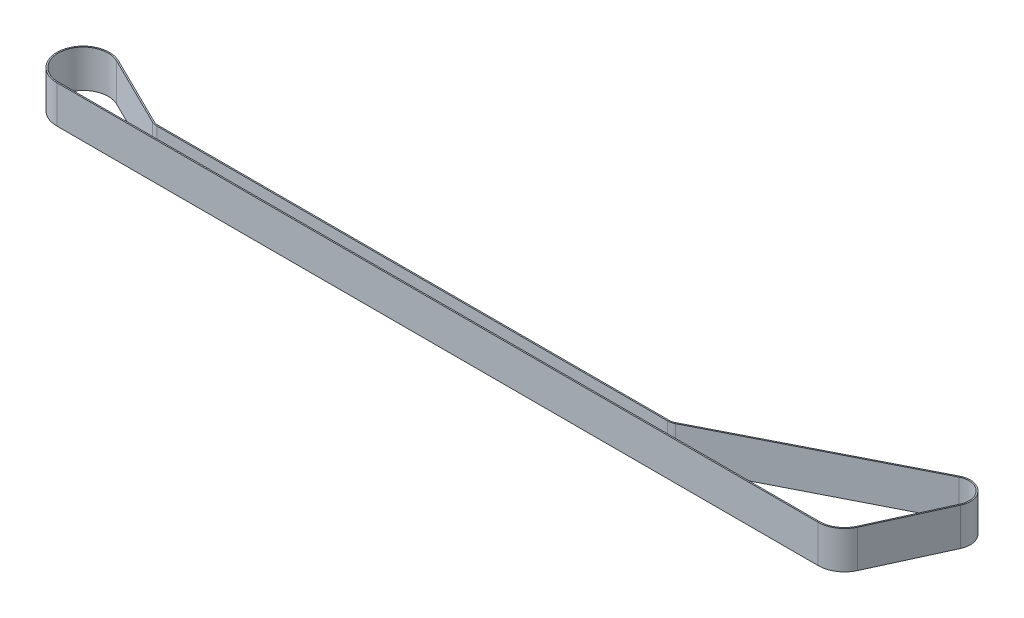
from build123d import *

# Parameters (mm, degrees)
BOSS_EXTRUDE1_DEPTH = 15


with BuildPart() as part:
    # Sketch1 → Boss-Extrude1 (new body)
    with BuildSketch(Plane(origin=(0, 0, 0), x_dir=(1, 0, 0), z_dir=(0, 1, 0))):
        with BuildLine():
            Line((238.84, -5), (35, -5))
            ThreePointArc((35, -5), (33.863075353, -4.869024784), (32.785714286, -4.482960938))
            Line((32.785714286, -4.482960938), (4.65, 9.414217971))
            ThreePointArc((4.65, 9.414217971), (-10.224952046, 2.38754176), (0, -10.5))
            Line((0, -10.5), (303.94, -10.5))
            ThreePointArc((303.94, -10.5), (309.61007222, -8.837436338), (313.484552814, -4.376244004))
            Line((313.484552814, -4.376244004), (326.437537724, 23.874111425))
            ThreePointArc((326.437537724, 23.874111425), (324.816305533, 32.408179805), (316.224290262, 33.687238247))
            Line((316.224290262, 33.687238247), (241.103806492, -4.458158831))
            ThreePointArc((241.103806492, -4.458158831), (240.0038741, -4.862653296), (238.84, -5))
        make_face()
        with BuildLine():
            Line((0, -10), (303.94, -10))
            ThreePointArc((303.94, -10), (309.340068781, -8.416606036), (313.030050299, -4.167851433))
            Line((313.030050299, -4.167851433), (325.983035209, 24.082503997))
            ThreePointArc((325.983035209, 24.082503997), (324.469885164, 32.047634485), (316.450670911, 33.241422364))
            Line((316.450670911, 33.241422364), (241.330187142, -4.903974714))
            ThreePointArc((241.330187142, -4.903974714), (240.12026151, -5.348918626), (238.84, -5.5))
            Line((238.84, -5.5), (35, -5.5))
            ThreePointArc((35, -5.5), (33.749382888, -5.355927262), (32.564285714, -4.931257032))
            Line((32.564285714, -4.931257032), (4.428571429, 8.965921877))
            ThreePointArc((4.428571429, 8.965921877), (-9.738049568, 2.273849295), (0, -10))
        make_face(mode=Mode.SUBTRACT)
    extrude(amount=BOSS_EXTRUDE1_DEPTH)


solid = part.part
